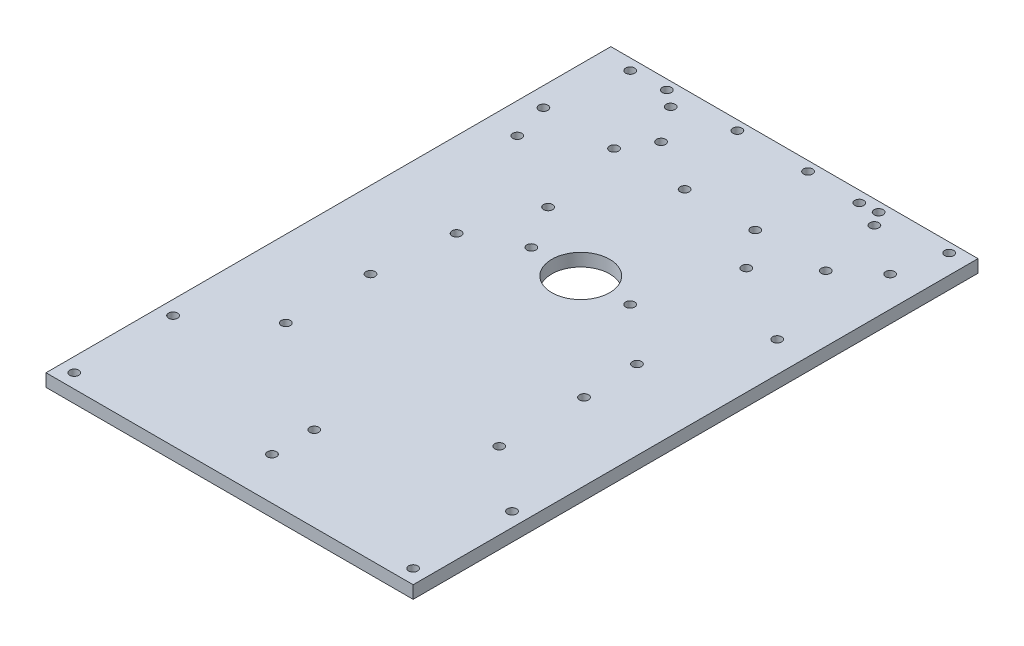
from build123d import *

# Parameters (mm, degrees)
SKETCH1_W           = 130
SKETCH1_H           = 200
BOSS_EXTRUDE1_DEPTH = 4.5
SKETCH3_R           = 1.6
CUT_EXTRUDE1_DEPTH  = 4.5
SKETCH4_R           = 1.6
CUT_EXTRUDE2_DEPTH  = 4.5
SKETCH5_R           = 1.6
CUT_EXTRUDE3_DEPTH  = 4.5
SKETCH6_R           = 1.6
CUT_EXTRUDE4_DEPTH  = 4.5
SKETCH7_R           = 1.6
CUT_EXTRUDE5_DEPTH  = 4.5
SKETCH9_R           = 1.6
SKETCH9_R_2         = 10.25
CUT_EXTRUDE6_DEPTH  = 4.5


with BuildPart() as part:
    # Sketch1 → Boss-Extrude1 (new body)
    with BuildSketch(Plane(origin=(0, 0, 0), x_dir=(1, 0, 0), z_dir=(0, 1, 0))):
        Rectangle(SKETCH1_W, SKETCH1_H)
    extrude(amount=BOSS_EXTRUDE1_DEPTH)

    # Sketch3 → Cut-Extrude1 (cut)
    with BuildSketch(Plane(origin=(0, 0, 0), x_dir=(1, 0, 0), z_dir=(0, 1, 0))):
        with Locations((-60, -95)):
            Circle(SKETCH3_R)
        with Locations((60, -95)):
            Circle(SKETCH3_R)
        with Locations((-60, -60)):
            Circle(SKETCH3_R)
        with Locations((60, -60)):
            Circle(SKETCH3_R)
    extrude(amount=CUT_EXTRUDE1_DEPTH, mode=Mode.SUBTRACT)

    # Sketch4 → Cut-Extrude2 (cut)
    with BuildSketch(Plane(origin=(0, 0, 0), x_dir=(1, 0, 0), z_dir=(0, 1, 0))):
        with Locations((-35.055, 15.432)):
            Circle(SKETCH4_R)
        with Locations((36.957, 7.29)):
            Circle(SKETCH4_R)
        with Locations((36.445, 91.87)):
            Circle(SKETCH4_R)
        with Locations((-35.945, 92.13)):
            Circle(SKETCH4_R)
    extrude(amount=CUT_EXTRUDE2_DEPTH, mode=Mode.SUBTRACT)

    # Sketch5 → Cut-Extrude3 (cut)
    with BuildSketch(Plane(origin=(0, 0, 0), x_dir=(1, 0, 0), z_dir=(0, 1, 0))):
        with Locations((37.8, -12.298)):
            Circle(SKETCH5_R)
        with Locations((37.8, -42.298)):
            Circle(SKETCH5_R)
        with Locations((-37.8, -42.298)):
            Circle(SKETCH5_R)
        with Locations((-37.8, -12.298)):
            Circle(SKETCH5_R)
    extrude(amount=CUT_EXTRUDE3_DEPTH, mode=Mode.SUBTRACT)

    # Sketch6 → Cut-Extrude4 (cut)
    with BuildSketch(Plane(origin=(0, 0, 0), x_dir=(1, 0, 0), z_dir=(0, 1, 0))):
        with Locations((54.21, 79.68)):
            Circle(SKETCH6_R)
        with Locations((26.904, 96.063)):
            Circle(SKETCH6_R)
        with Locations((26.904, 56.063)):
            Circle(SKETCH6_R)
        with Locations((54.21, 39.68)):
            Circle(SKETCH6_R)
        with Locations((-54.21, 96.063)):
            Circle(SKETCH6_R)
        with Locations((-26.904, 79.68)):
            Circle(SKETCH6_R)
        with Locations((-54.21, 56.063)):
            Circle(SKETCH6_R)
        with Locations((-26.904, 39.68)):
            Circle(SKETCH6_R)
    extrude(amount=CUT_EXTRUDE4_DEPTH, mode=Mode.SUBTRACT)

    # Sketch7 → Cut-Extrude5 (cut)
    with BuildSketch(Plane(origin=(0, 0, 0), x_dir=(1, 0, 0), z_dir=(0, 1, 0))):
        with Locations((-8.1915, 69.312)):
            Circle(SKETCH7_R)
        with Locations((8.1915, 96.618)):
            Circle(SKETCH7_R)
        with Locations((16.8085, 69.312)):
            Circle(SKETCH7_R)
        with Locations((33.1915, 96.618)):
            Circle(SKETCH7_R)
        with Locations((41.8085, 69.312)):
            Circle(SKETCH7_R)
        with Locations((58.1915, 96.618)):
            Circle(SKETCH7_R)
        with Locations((-33.1915, 69.312)):
            Circle(SKETCH7_R)
        with Locations((-16.8085, 96.618)):
            Circle(SKETCH7_R)
        with Locations((-58.1915, 69.312)):
            Circle(SKETCH7_R)
        with Locations((-41.8085, 96.618)):
            Circle(SKETCH7_R)
    extrude(amount=CUT_EXTRUDE5_DEPTH, mode=Mode.SUBTRACT)

    # Sketch9 → Cut-Extrude6 (cut)
    with BuildSketch(Plane(origin=(0, 0, 0), x_dir=(1, 0, 0), z_dir=(0, 1, 0))):
        with Locations((0, -70)):
            Circle(SKETCH9_R)
        with Locations((0, -85)):
            Circle(SKETCH9_R)
        with Locations((0, 24.345540537)):
            Circle(SKETCH9_R_2)
        with Locations((17.5, 24.345540537)):
            Circle(SKETCH9_R)
        with Locations((-17.5, 24.345540537)):
            Circle(SKETCH9_R)
    extrude(amount=CUT_EXTRUDE6_DEPTH, mode=Mode.SUBTRACT)


solid = part.part
